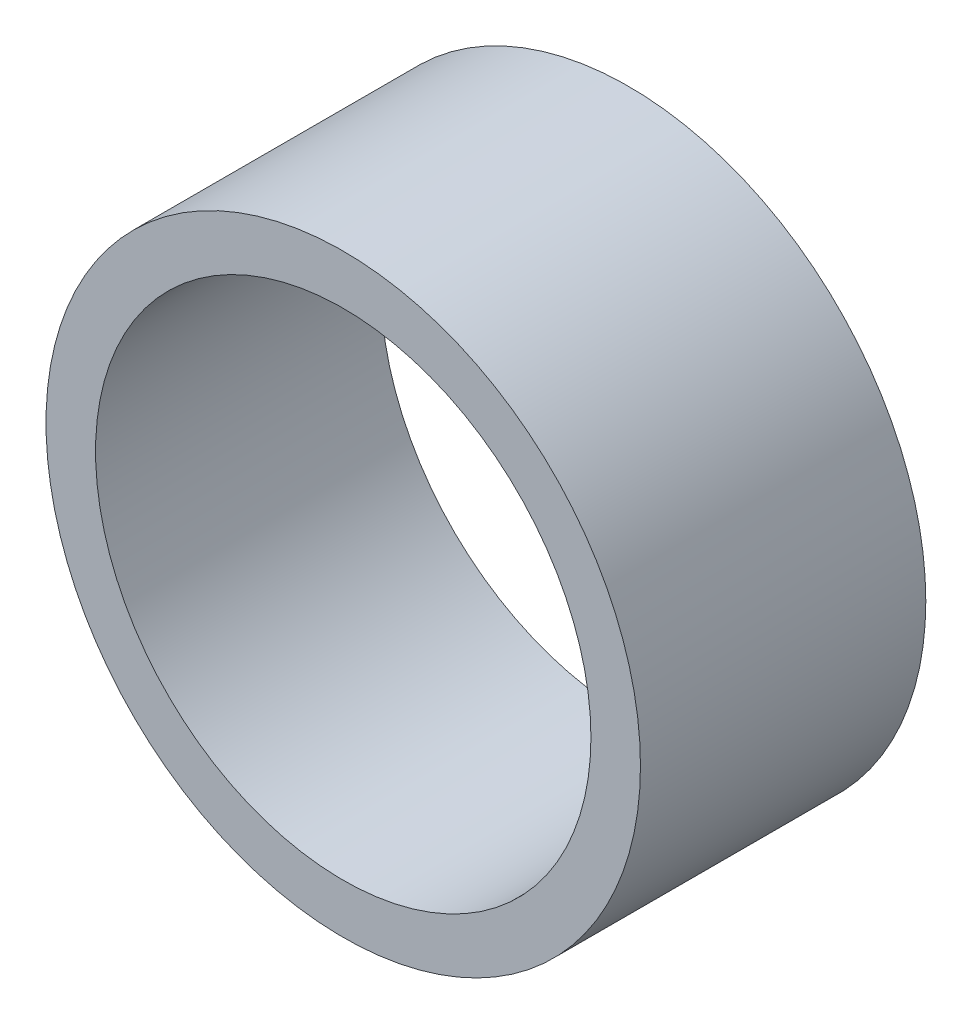
from build123d import *

# Parameters (mm, degrees)
SZKIC1_R                    = 15
SZKIC1_R_2                  = 12.5
DODANIE_WYCI_GNI_CIE1_DEPTH = 14.4


with BuildPart() as part:
    # Szkic1 → Dodanie-wyciągnięcie1 (new body)
    with BuildSketch(Plane.XY):
        Circle(SZKIC1_R)
        Circle(SZKIC1_R_2, mode=Mode.SUBTRACT)
    extrude(amount=DODANIE_WYCI_GNI_CIE1_DEPTH)


solid = part.part
